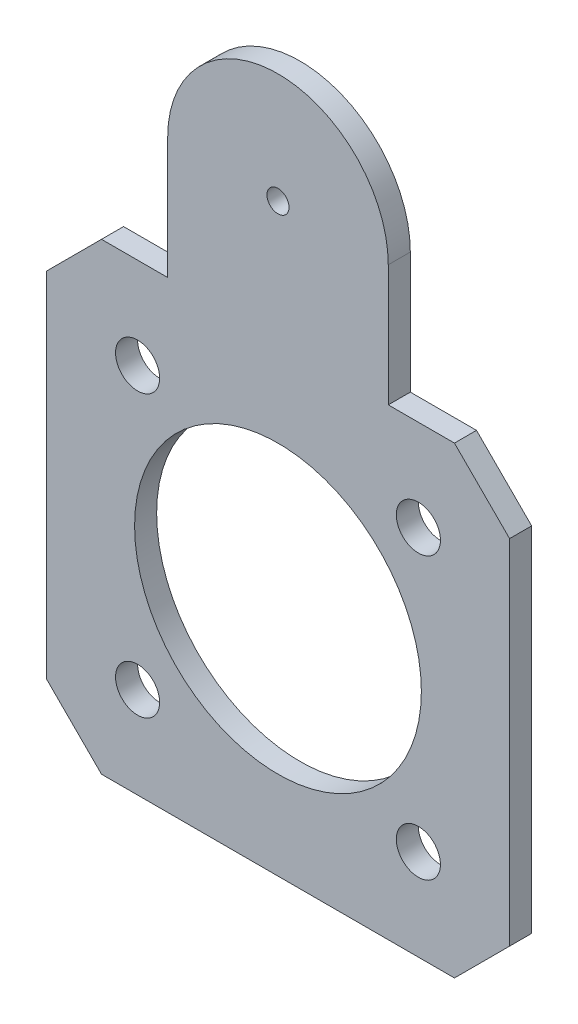
from build123d import *

# Parameters (mm, degrees)
CROQUIS1_R              = 2
CROQUIS1_R_2            = 13
CROQUIS1_R_3            = 1
SALIENTE_EXTRUIR1_DEPTH = 2


with BuildPart() as part:
    # Croquis1 → Saliente-Extruir1 (new body)
    with BuildSketch(Plane.XY):
        with BuildLine():
            Line((10, 21), (16, 21))
            Line((16, 21), (21, 16))
            Line((21, 16), (21, -16))
            Line((21, -16), (16, -21))
            Line((16, -21), (-16, -21))
            Line((-16, -21), (-21, -16))
            Line((-21, -16), (-21, 16))
            Line((-21, 16), (-16, 21))
            Line((-16, 21), (-10, 21))
            Line((-10, 21), (-10, 32))
            ThreePointArc((-10, 32), (0, 42), (10, 32))
            Line((10, 32), (10, 21))
        make_face()
        with Locations((12.727922061, 12.727922061)):
            Circle(CROQUIS1_R, mode=Mode.SUBTRACT)
        with Locations((12.727922061, -12.727922061)):
            Circle(CROQUIS1_R, mode=Mode.SUBTRACT)
        with Locations((-12.727922061, -12.727922061)):
            Circle(CROQUIS1_R, mode=Mode.SUBTRACT)
        with Locations((-12.727922061, 12.727922061)):
            Circle(CROQUIS1_R, mode=Mode.SUBTRACT)
        Circle(CROQUIS1_R_2, mode=Mode.SUBTRACT)
        with Locations((0, 32)):
            Circle(CROQUIS1_R_3, mode=Mode.SUBTRACT)
    extrude(amount=SALIENTE_EXTRUIR1_DEPTH)


solid = part.part
